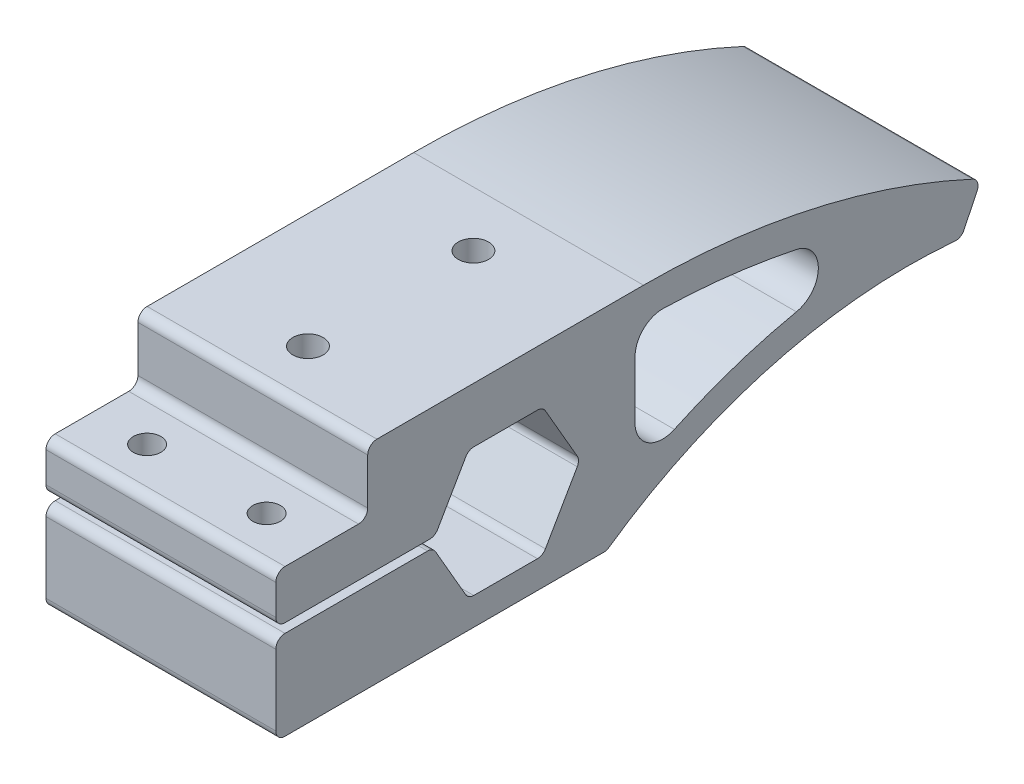
from build123d import *

# Parameters (mm, degrees)
BOSS_EXTRUDE1_DEPTH   = 25
FILLET1_R             = 1
F_3_0MM_DOWEL_HOLE1_D = 3
M4_TAPPED_HOLE1_D     = 3.3
M4_TAPPED_HOLE1_DEPTH = 10.1
M4_TAPPED_HOLE1_TIP   = 0.991420021


with BuildPart() as part:
    # Sketch1 → Boss-Extrude1 (new body)
    with BuildSketch(Plane(origin=(0, 0, 0), x_dir=(0, 0, -1), z_dir=(1, 0, 0))):
        with BuildLine():
            Line((0, 85), (-30, 85))
            Line((-30, 85), (-30, 78))
            Line((-30, 78), (-40, 78))
            Line((-40, 78), (-40, 72.7))
            Line((-40, 72.7), (-22.67875858, 72.7))
            Line((-22.67875858, 72.7), (-19.041451884, 79))
            Line((-19.041451884, 79), (-10.958548116, 79))
            Line((-10.958548116, 79), (-6.917096231, 72))
            Line((-6.917096231, 72), (-10.958548116, 65))
            Line((-10.958548116, 65), (-19.041451884, 65))
            Line((-19.041451884, 65), (-22.909698688, 71.7))
            Line((-22.909698688, 71.7), (-40, 71.7))
            Line((-40, 71.7), (-40, 62))
            Line((-40, 62), (-4, 62))
            ThreePointArc((-4, 62), (14.367926682, 70.556066939), (34.568411175, 72.145858848))
            Line((34.568411175, 72.145858848), (36.728936873, 76.654975026))
            ThreePointArc((36.728936873, 76.654975026), (18.832513412, 82.887492655), (0, 85))
        make_face()
        with BuildLine():
            Line((-0.917096231, 72.45580085), (-0.917096231, 78.731121633))
            ThreePointArc((-0.917096231, 78.731121633), (-0.009883557, 80.880596268), (2.163064575, 81.730050482))
            ThreePointArc((2.163064575, 81.730050482), (9.436412465, 81.210823112), (16.634722164, 80.046553355))
            ThreePointArc((16.634722164, 80.046553355), (19.024323748, 77.110478101), (16.637014487, 74.172538667))
            ThreePointArc((16.637014487, 74.172538667), (9.867798138, 72.343342951), (3.357045186, 69.739817851))
            ThreePointArc((3.357045186, 69.739817851), (0.473932708, 69.9237637), (-0.917096231, 72.45580085))
        make_face(mode=Mode.SUBTRACT)
    extrude(amount=BOSS_EXTRUDE1_DEPTH)

    # Fillet1
    fillet1_edges = [part.edges().sort_by_distance(p)[0] for p in [
        (12.5, 76.654975026, -36.728936873),
        (12.5, 72.145858848, -34.568411175),
        (12.5, 62, 4),
        (12.5, 62, 40),
        (12.5, 71.7, 40),
        (12.5, 71.7, 22.909698688),
        (12.5, 65, 19.041451884),
        (12.5, 65, 10.958548116),
        (12.5, 72, 6.917096231),
        (12.5, 79, 10.958548116),
        (12.5, 79, 19.041451884),
        (12.5, 72.7, 22.67875858),
        (12.5, 72.7, 40),
        (12.5, 78, 40),
        (12.5, 78, 30),
        (12.5, 85, 30),
    ]]
    fillet(fillet1_edges, radius=FILLET1_R)

    # Ø3.0mm Dowel Hole1 (through all)
    with Locations(Plane(origin=(0, 78, 0), x_dir=(1, 0, 0), z_dir=(0, 1, 0))):
        with Locations((6, -35), (19, -35)):
            Hole(F_3_0MM_DOWEL_HOLE1_D / 2)

    # M4 Tapped Hole1
    with Locations(Plane(origin=(0, 85, 0), x_dir=(1, 0, 0), z_dir=(0, 1, 0))):
        with Locations((12.5, -24), (12.5, -6)):
            Hole(M4_TAPPED_HOLE1_D / 2, depth=M4_TAPPED_HOLE1_DEPTH)
            with Locations((0, 0, -(M4_TAPPED_HOLE1_DEPTH + M4_TAPPED_HOLE1_TIP / 2))):  # 118° drill point
                Cone(0, M4_TAPPED_HOLE1_D / 2, M4_TAPPED_HOLE1_TIP, mode=Mode.SUBTRACT)


solid = part.part
